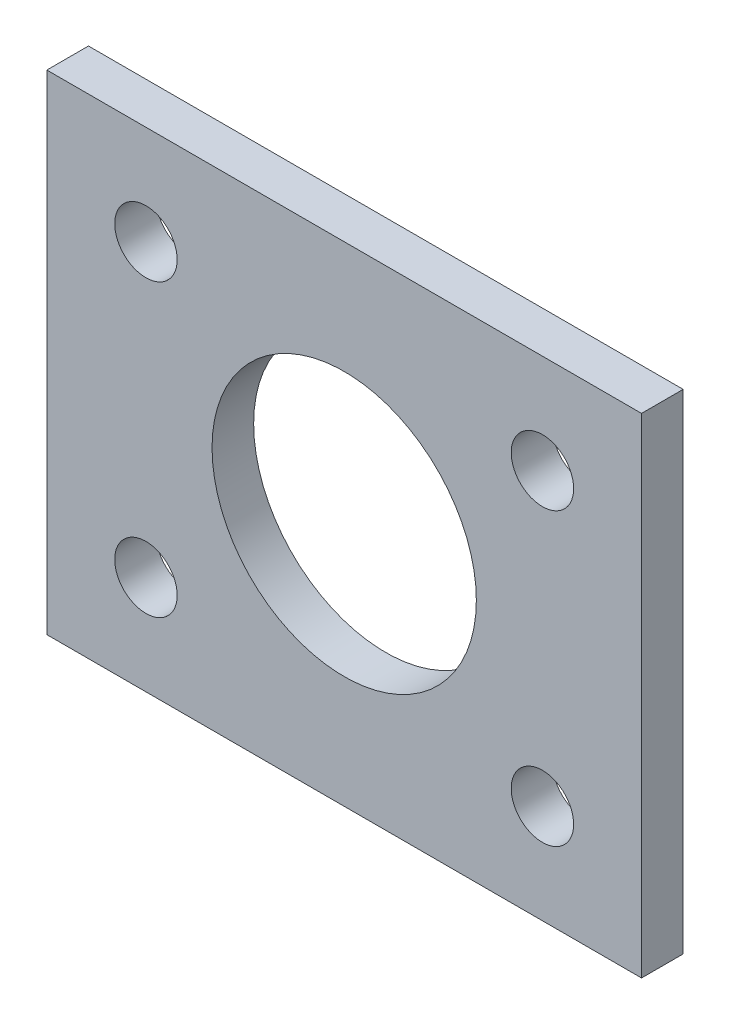
from build123d import *

# Parameters (mm, degrees)
SKETCH5_W           = 28.575
SKETCH5_H           = 23.495
SKETCH5_R           = 1.5
SKETCH5_R_2         = 6.35
BOSS_EXTRUDE1_DEPTH = 2


with BuildPart() as part:
    # Sketch5 → Boss-Extrude1 (new body)
    with BuildSketch(Plane.XY):
        Rectangle(SKETCH5_W, SKETCH5_H)
        with Locations((-9.525, 6.985)):
            Circle(SKETCH5_R, mode=Mode.SUBTRACT)
        with Locations((9.525, 6.985)):
            Circle(SKETCH5_R, mode=Mode.SUBTRACT)
        with Locations((-9.525, -6.985)):
            Circle(SKETCH5_R, mode=Mode.SUBTRACT)
        with Locations((9.525, -6.985)):
            Circle(SKETCH5_R, mode=Mode.SUBTRACT)
        Circle(SKETCH5_R_2, mode=Mode.SUBTRACT)
    extrude(amount=BOSS_EXTRUDE1_DEPTH)


solid = part.part
